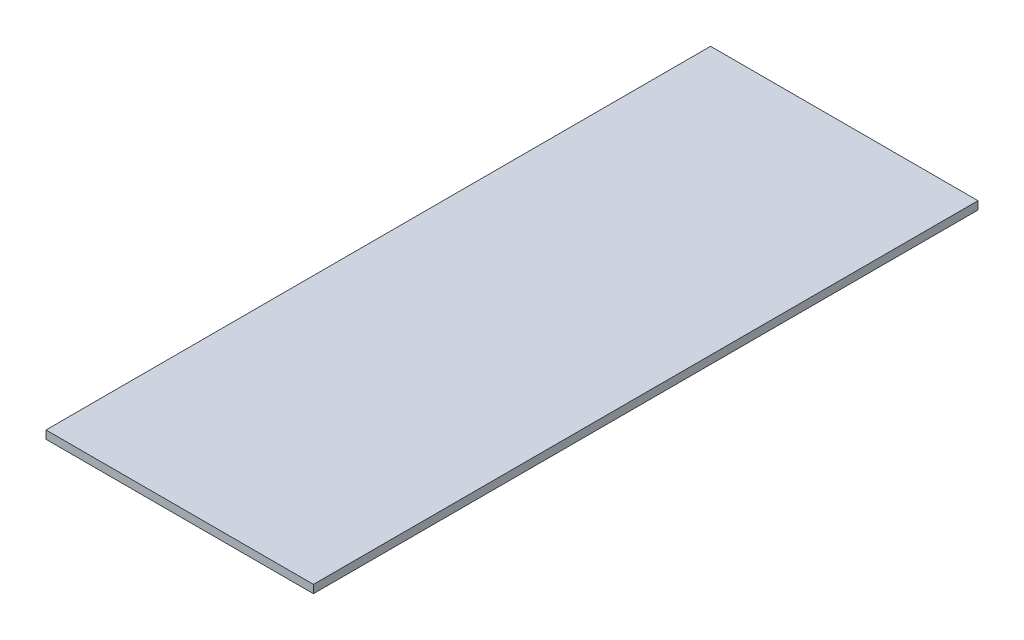
from build123d import *

# Parameters (mm, degrees)
SKETCH1_W           = 66
SKETCH1_H           = 164
BOSS_EXTRUDE1_DEPTH = 2


with BuildPart() as part:
    # Sketch1 → Boss-Extrude1 (new body)
    with BuildSketch(Plane(origin=(0, 0, 0), x_dir=(1, 0, 0), z_dir=(0, 1, 0))):
        Rectangle(SKETCH1_W, SKETCH1_H)
    extrude(amount=BOSS_EXTRUDE1_DEPTH)


solid = part.part
